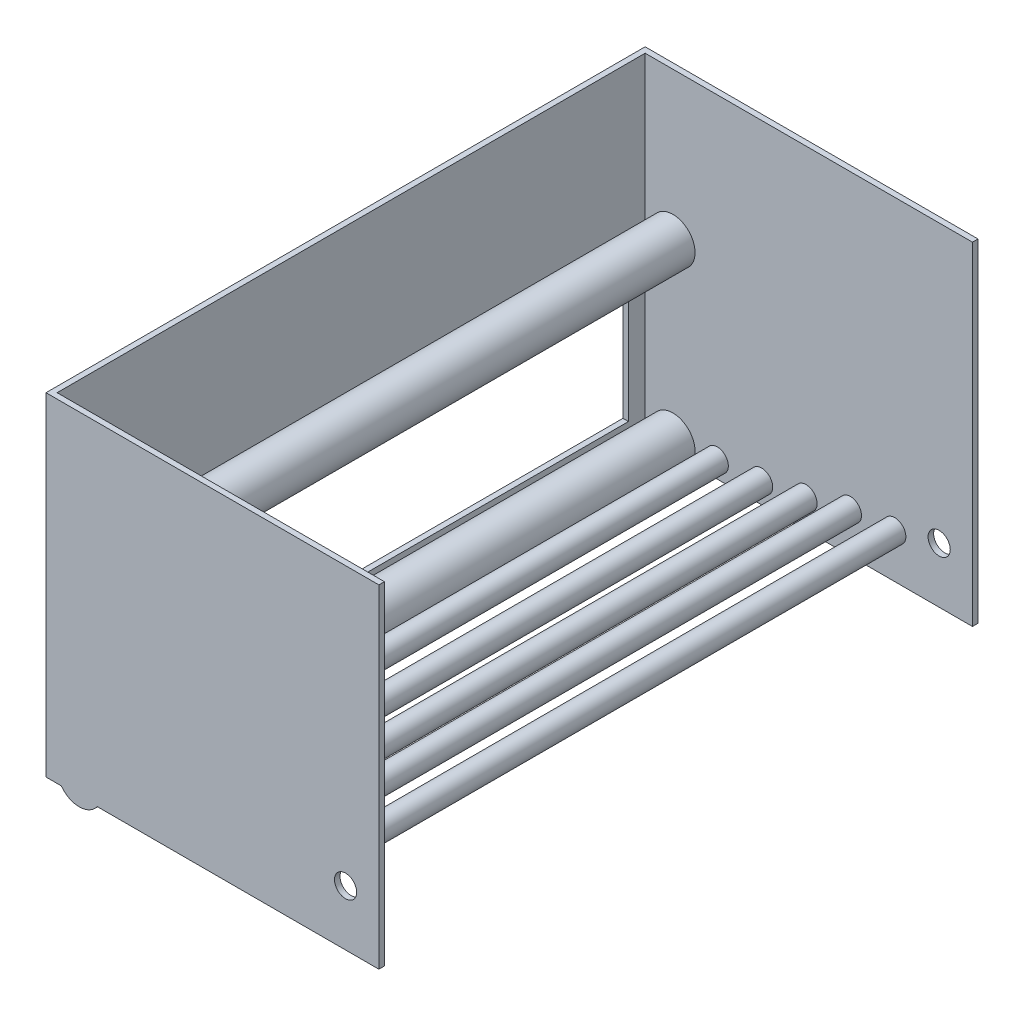
from build123d import *

# Parameters (mm, degrees)
SKETCH1_W               = 381
SKETCH1_H               = 685.8
BOSS_EXTRUDE1_DEPTH     = 381
SHELL1_T                = -6.35
SKETCH4_R               = 12.7
CUT_EXTRUDE1_DEPTH      = 1
CUT_EXTRUDE1_DEPTH_BACK = 686.8
SKETCH5_R               = 12.7
BOSS_EXTRUDE3_DEPTH     = 679.45
SKETCH6_R               = 25.4
BOSS_EXTRUDE4_DEPTH     = 679.45
CUT_EXTRUDE3_REACH      = 8.35
SKETCH7_W               = 635
SKETCH7_H               = 165.1


with BuildPart() as part:
    # Sketch1 → Boss-Extrude1 (new body)
    with BuildSketch(Plane(origin=(0, 0, 0), x_dir=(1, 0, 0), z_dir=(0, 1, 0))):
        with Locations((190.5, 342.9)):
            Rectangle(SKETCH1_W, SKETCH1_H)
    extrude(amount=BOSS_EXTRUDE1_DEPTH)

    # Shell1
    shell1_openings = [part.faces().sort_by_distance(p)[0] for p in [
        (190.5, 381, -342.9),
        (190.5, 0, -342.9),
        (381, 190.5, -342.9),
    ]]
    offset(amount=SHELL1_T, openings=shell1_openings, kind=Kind.INTERSECTION)

    # Sketch4 → Cut-Extrude1 (cut, two sides)
    with BuildSketch(Plane.XY) as cut_extrude1_sk:
        with Locations((342.9, 63.5)):
            Circle(SKETCH4_R)
    extrude(amount=CUT_EXTRUDE1_DEPTH, mode=Mode.SUBTRACT)
    extrude(cut_extrude1_sk.sketch, amount=-CUT_EXTRUDE1_DEPTH_BACK, mode=Mode.SUBTRACT)

    # Sketch5 → Boss-Extrude3 (add)
    with BuildSketch(Plane.XY):
        with Locations((292.1, 50.8)):
            Circle(SKETCH5_R)
        with Locations((190.5, 32.743756917)):
            Circle(SKETCH5_R)
        with Locations((88.9, 19.34192219)):
            Circle(SKETCH5_R)
        with Locations((241.3, 46.355575893)):
            Circle(SKETCH5_R)
        with Locations((139.7, 23.786346297)):
            Circle(SKETCH5_R)
    extrude(amount=-BOSS_EXTRUDE3_DEPTH)

    # Sketch6 → Boss-Extrude4 (add)
    with BuildSketch(Plane.XY):
        with Locations((38.1, 14.897498083)):
            Circle(SKETCH6_R)
        with Locations((38.1, 211.747498083)):
            Circle(SKETCH6_R)
    extrude(amount=-BOSS_EXTRUDE4_DEPTH)

    # Sketch7 → Cut-Extrude3 (cut, up to next)
    with BuildSketch(Plane(origin=(6.35, 0, 0), x_dir=(0, 0, -1), z_dir=(1, 0, 0)), mode=Mode.PRIVATE) as cut_extrude3_sk1:
        with Locations((342.9, 107.95)):
            Rectangle(SKETCH7_W, SKETCH7_H)
    cut_extrude3_tool1 = extrude(cut_extrude3_sk1.sketch, amount=-CUT_EXTRUDE3_REACH, mode=Mode.PRIVATE) & part.part
    add(cut_extrude3_tool1.solids().sort_by_distance((6.35, 107.95, -342.9))[0], mode=Mode.SUBTRACT)


solid = part.part
